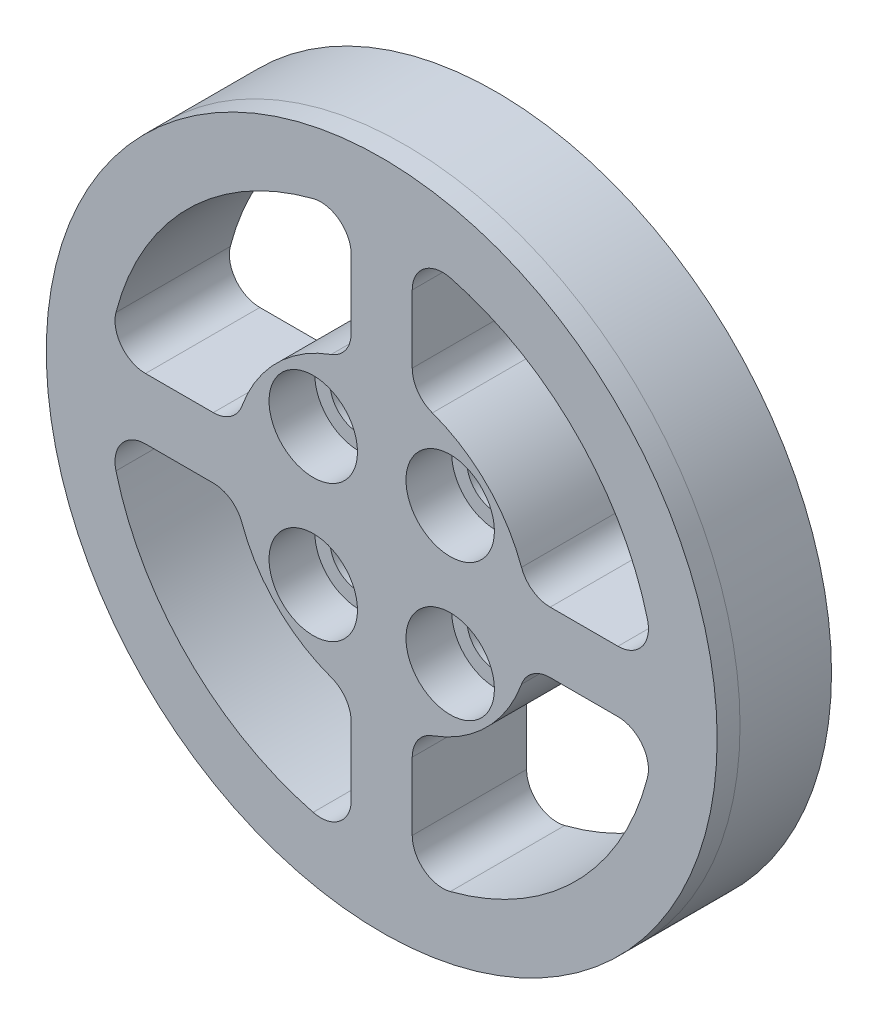
from build123d import *

# Parameters (mm, degrees)
SKETCH1_R           = 22
BOSS_EXTRUDE1_DEPTH = 6
BOSS_EXTRUDE2_DEPTH = 1.5
SKETCH3_R           = 1.375
BOSS_EXTRUDE3_DEPTH = 2.5
CUT_EXTRUDE3_REACH  = 12
SKETCH6_R           = 1.9
SKETCH7_R           = 2.9
CUT_EXTRUDE4_DEPTH  = 3
CUT_EXTRUDE5_START  = -1.5
SKETCH8_R           = 23.24877744
SKETCH8_R_2         = 22.000061981
CUT_EXTRUDE5_DEPTH  = 1.5


with BuildPart() as part:
    # Sketch1 → Boss-Extrude1 (new body)
    with BuildSketch(Plane.XY):
        Circle(SKETCH1_R)
        with BuildLine():
            Line((11.048189897, 2), (15.491933385, 2))
            ThreePointArc((15.491933385, 2), (17.073072215, 2.775255129), (17.428425058, 4.5))
            ThreePointArc((17.428425058, 4.5), (12.727922061, 12.727922061), (4.5, 17.428425058))
            ThreePointArc((4.5, 17.428425058), (2.775255129, 17.073072215), (2, 15.491933385))
            Line((2, 15.491933385), (2, 11.048189897))
            ThreePointArc((2, 11.048189897), (2.362669531, 9.899647805), (3.319148936, 9.167646936))
            ThreePointArc((3.319148936, 9.167646936), (6.894291117, 6.894291117), (9.167646936, 3.319148936))
            ThreePointArc((9.167646936, 3.319148936), (9.899647805, 2.362669531), (11.048189897, 2))
        make_face(mode=Mode.SUBTRACT)
        with BuildLine():
            Line((-15.491933385, 2), (-11.048189897, 2))
            ThreePointArc((-11.048189897, 2), (-9.899647805, 2.362669531), (-9.167646936, 3.319148936))
            ThreePointArc((-9.167646936, 3.319148936), (-6.894291117, 6.894291117), (-3.319148936, 9.167646936))
            ThreePointArc((-3.319148936, 9.167646936), (-2.362669531, 9.899647805), (-2, 11.048189897))
            Line((-2, 11.048189897), (-2, 15.491933385))
            ThreePointArc((-2, 15.491933385), (-2.775255129, 17.073072215), (-4.5, 17.428425058))
            ThreePointArc((-4.5, 17.428425058), (-12.727922061, 12.727922061), (-17.428425058, 4.5))
            ThreePointArc((-17.428425058, 4.5), (-17.073072215, 2.775255129), (-15.491933385, 2))
        make_face(mode=Mode.SUBTRACT)
        with BuildLine():
            Line((2, -11.048189897), (2, -15.491933385))
            ThreePointArc((2, -15.491933385), (2.775255129, -17.073072215), (4.5, -17.428425058))
            ThreePointArc((4.5, -17.428425058), (12.727922061, -12.727922061), (17.428425058, -4.5))
            ThreePointArc((17.428425058, -4.5), (17.073072215, -2.775255129), (15.491933385, -2))
            Line((15.491933385, -2), (11.048189897, -2))
            ThreePointArc((11.048189897, -2), (9.899647805, -2.362669531), (9.167646936, -3.319148936))
            ThreePointArc((9.167646936, -3.319148936), (6.894291117, -6.894291117), (3.319148936, -9.167646936))
            ThreePointArc((3.319148936, -9.167646936), (2.362669531, -9.899647805), (2, -11.048189897))
        make_face(mode=Mode.SUBTRACT)
        with BuildLine():
            Line((-15.491933385, -2), (-11.048189897, -2))
            ThreePointArc((-11.048189897, -2), (-9.899647805, -2.362669531), (-9.167646936, -3.319148936))
            ThreePointArc((-9.167646936, -3.319148936), (-6.894291117, -6.894291117), (-3.319148936, -9.167646936))
            ThreePointArc((-3.319148936, -9.167646936), (-2.362669531, -9.899647805), (-2, -11.048189897))
            Line((-2, -11.048189897), (-2, -15.491933385))
            ThreePointArc((-2, -15.491933385), (-2.775255129, -17.073072215), (-4.5, -17.428425058))
            ThreePointArc((-4.5, -17.428425058), (-12.727922061, -12.727922061), (-17.428425058, -4.5))
            ThreePointArc((-17.428425058, -4.5), (-17.073072215, -2.775255129), (-15.491933385, -2))
        make_face(mode=Mode.SUBTRACT)
    extrude(amount=BOSS_EXTRUDE1_DEPTH)

    # Sketch2 → Boss-Extrude2 (add)
    with BuildSketch(Plane.XY.offset(6)):
        with BuildLine():
            Line((-4.587705573, 22.79163465), (-6.529589207, 22.313003321))
            ThreePointArc((-6.529589207, 22.313003321), (-6.910364179, 21.255540917), (-7.801329494, 20.570415293))
            ThreePointArc((-7.801329494, 20.570415293), (-8.922548934, 20.492419898), (-9.908790373, 21.031441363))
            Line((-9.908790373, 21.031441363), (-11.679702424, 20.101995018))
            ThreePointArc((-11.679702424, 20.101995018), (-11.796345449, 18.984135135), (-12.497459637, 18.105696059))
            ThreePointArc((-12.497459637, 18.105696059), (-13.567432959, 17.761641694), (-14.654012294, 18.048977149))
            Line((-14.654012294, 18.048977149), (-16.15103379, 16.722731833))
            ThreePointArc((-16.15103379, 16.722731833), (-15.996766, 15.609440423), (-16.467282853, 14.588739582))
            ThreePointArc((-16.467282853, 14.588739582), (-17.423827096, 13.998621436), (-18.547596285, 14.017571989))
            Line((-18.547596285, 14.017571989), (-19.683725779, 12.371604258))
            ThreePointArc((-19.683725779, 12.371604258), (-19.267512657, 11.327581771), (-19.480087446, 10.223938589))
            ThreePointArc((-19.480087446, 10.223938589), (-20.267611735, 9.422052183), (-21.363261398, 9.171516497))
            Line((-21.363261398, 9.171516497), (-22.072471173, 7.301484012))
            ThreePointArc((-22.072471173, 7.301484012), (-21.418501513, 6.387405241), (-21.360780164, 5.264959447))
            ThreePointArc((-21.360780164, 5.264959447), (-21.93351645, 4.297907504), (-22.937371411, 3.792445804))
            Line((-22.937371411, 3.792445804), (-23.178444772, 1.807028055))
            ThreePointArc((-23.178444772, 1.807028055), (-22.324724914, 1.076015936), (-22.000061981, 0))
            ThreePointArc((-22.000061981, 0), (-22.324724914, -1.076015936), (-23.178444772, -1.807028055))
            Line((-23.178444772, -1.807028055), (-22.937371411, -3.792445804))
            ThreePointArc((-22.937371411, -3.792445804), (-21.93351645, -4.297907504), (-21.360780164, -5.264959447))
            ThreePointArc((-21.360780164, -5.264959447), (-21.418501513, -6.387405241), (-22.072471173, -7.301484012))
            Line((-22.072471173, -7.301484012), (-21.363261398, -9.171516497))
            ThreePointArc((-21.363261398, -9.171516497), (-20.267611735, -9.422052183), (-19.480087446, -10.223938589))
            ThreePointArc((-19.480087446, -10.223938589), (-19.267512657, -11.327581771), (-19.683725779, -12.371604258))
            Line((-19.683725779, -12.371604258), (-18.547596285, -14.017571989))
            ThreePointArc((-18.547596285, -14.017571989), (-17.423827096, -13.998621436), (-16.467282853, -14.588739582))
            ThreePointArc((-16.467282853, -14.588739582), (-15.996766, -15.609440423), (-16.15103379, -16.722731833))
            Line((-16.15103379, -16.722731833), (-14.654012294, -18.048977149))
            ThreePointArc((-14.654012294, -18.048977149), (-13.567432959, -17.761641694), (-12.497459637, -18.105696059))
            ThreePointArc((-12.497459637, -18.105696059), (-11.796345449, -18.984135135), (-11.679702424, -20.101995018))
            Line((-11.679702424, -20.101995018), (-9.908790373, -21.031441363))
            ThreePointArc((-9.908790373, -21.031441363), (-8.922548934, -20.492419898), (-7.801329494, -20.570415293))
            ThreePointArc((-7.801329494, -20.570415293), (-6.910364179, -21.255540917), (-6.529589207, -22.313003321))
            Line((-6.529589207, -22.313003321), (-4.587705573, -22.79163465))
            ThreePointArc((-4.587705573, -22.79163465), (-3.759118797, -22.032253145), (-2.651814437, -21.839656759))
            ThreePointArc((-2.651814437, -21.839656759), (-1.62277766, -22.291651923), (-1, -23.227260976))
            Line((-1, -23.227260976), (1, -23.227260976))
            ThreePointArc((1, -23.227260976), (1.62277766, -22.291651923), (2.651814437, -21.839656759))
            ThreePointArc((2.651814437, -21.839656759), (3.759118797, -22.032253145), (4.587705573, -22.79163465))
            Line((4.587705573, -22.79163465), (6.529589207, -22.313003321))
            ThreePointArc((6.529589207, -22.313003321), (6.910364179, -21.255540917), (7.801329494, -20.570415293))
            ThreePointArc((7.801329494, -20.570415293), (8.922548934, -20.492419898), (9.908790373, -21.031441363))
            Line((9.908790373, -21.031441363), (11.679702424, -20.101995018))
            ThreePointArc((11.679702424, -20.101995018), (11.796345449, -18.984135135), (12.497459637, -18.105696059))
            ThreePointArc((12.497459637, -18.105696059), (13.567432959, -17.761641694), (14.654012294, -18.048977149))
            Line((14.654012294, -18.048977149), (16.15103379, -16.722731833))
            ThreePointArc((16.15103379, -16.722731833), (15.996766, -15.609440423), (16.467282853, -14.588739582))
            ThreePointArc((16.467282853, -14.588739582), (17.423827096, -13.998621436), (18.547596285, -14.017571989))
            Line((18.547596285, -14.017571989), (19.683725779, -12.371604258))
            ThreePointArc((19.683725779, -12.371604258), (19.267512657, -11.327581771), (19.480087446, -10.223938589))
            ThreePointArc((19.480087446, -10.223938589), (20.267611735, -9.422052183), (21.363261398, -9.171516497))
            Line((21.363261398, -9.171516497), (22.072471173, -7.301484012))
            ThreePointArc((22.072471173, -7.301484012), (21.418501513, -6.387405241), (21.360780164, -5.264959447))
            ThreePointArc((21.360780164, -5.264959447), (21.93351645, -4.297907504), (22.937371411, -3.792445804))
            Line((22.937371411, -3.792445804), (23.178444772, -1.807028055))
            ThreePointArc((23.178444772, -1.807028055), (22.324724914, -1.076015936), (22.000061981, 0))
            ThreePointArc((22.000061981, 0), (22.324724914, 1.076015936), (23.178444772, 1.807028055))
            Line((23.178444772, 1.807028055), (22.937371411, 3.792445804))
            ThreePointArc((22.937371411, 3.792445804), (21.93351645, 4.297907504), (21.360780164, 5.264959447))
            ThreePointArc((21.360780164, 5.264959447), (21.418501513, 6.387405241), (22.072471173, 7.301484012))
            Line((22.072471173, 7.301484012), (21.363261398, 9.171516497))
            ThreePointArc((21.363261398, 9.171516497), (20.267611735, 9.422052183), (19.480087446, 10.223938589))
            ThreePointArc((19.480087446, 10.223938589), (19.267512657, 11.327581771), (19.683725779, 12.371604258))
            Line((19.683725779, 12.371604258), (18.547596285, 14.017571989))
            ThreePointArc((18.547596285, 14.017571989), (17.423827096, 13.998621436), (16.467282853, 14.588739582))
            ThreePointArc((16.467282853, 14.588739582), (15.996766, 15.609440423), (16.15103379, 16.722731833))
            Line((16.15103379, 16.722731833), (14.654012294, 18.048977149))
            ThreePointArc((14.654012294, 18.048977149), (13.567432959, 17.761641694), (12.497459637, 18.105696059))
            ThreePointArc((12.497459637, 18.105696059), (11.796345449, 18.984135135), (11.679702424, 20.101995018))
            Line((11.679702424, 20.101995018), (9.908790373, 21.031441363))
            ThreePointArc((9.908790373, 21.031441363), (8.922548934, 20.492419898), (7.801329494, 20.570415293))
            ThreePointArc((7.801329494, 20.570415293), (6.910364179, 21.255540917), (6.529589207, 22.313003321))
            Line((6.529589207, 22.313003321), (4.587705573, 22.79163465))
            ThreePointArc((4.587705573, 22.79163465), (3.759118797, 22.032253145), (2.651814437, 21.839656759))
            ThreePointArc((2.651814437, 21.839656759), (1.62277766, 22.291651923), (1, 23.227260976))
            Line((1, 23.227260976), (-1, 23.227260976))
            ThreePointArc((-1, 23.227260976), (-1.62277766, 22.291651923), (-2.651814437, 21.839656759))
            ThreePointArc((-2.651814437, 21.839656759), (-3.759118797, 22.032253145), (-4.587705573, 22.79163465))
        make_face()
        with BuildLine():
            Line((-2, 11.048189897), (-2, 15.491933385))
            ThreePointArc((-2, 15.491933385), (-2.775255129, 17.073072215), (-4.5, 17.428425058))
            ThreePointArc((-4.5, 17.428425058), (-12.727922061, 12.727922061), (-17.428425058, 4.5))
            ThreePointArc((-17.428425058, 4.5), (-17.073072215, 2.775255129), (-15.491933385, 2))
            Line((-15.491933385, 2), (-11.048189897, 2))
            ThreePointArc((-11.048189897, 2), (-9.899647805, 2.362669531), (-9.167646936, 3.319148936))
            ThreePointArc((-9.167646936, 3.319148936), (-6.894291117, 6.894291117), (-3.319148936, 9.167646936))
            ThreePointArc((-3.319148936, 9.167646936), (-2.362669531, 9.899647805), (-2, 11.048189897))
        make_face(mode=Mode.SUBTRACT)
        with BuildLine():
            Line((2, 15.491933385), (2, 11.048189897))
            ThreePointArc((2, 11.048189897), (2.362669531, 9.899647805), (3.319148936, 9.167646936))
            ThreePointArc((3.319148936, 9.167646936), (6.894291117, 6.894291117), (9.167646936, 3.319148936))
            ThreePointArc((9.167646936, 3.319148936), (9.899647805, 2.362669531), (11.048189897, 2))
            Line((11.048189897, 2), (15.491933385, 2))
            ThreePointArc((15.491933385, 2), (17.073072215, 2.775255129), (17.428425058, 4.5))
            ThreePointArc((17.428425058, 4.5), (12.727922061, 12.727922061), (4.5, 17.428425058))
            ThreePointArc((4.5, 17.428425058), (2.775255129, 17.073072215), (2, 15.491933385))
        make_face(mode=Mode.SUBTRACT)
        with BuildLine():
            Line((2, -11.048189897), (2, -15.491933385))
            ThreePointArc((2, -15.491933385), (2.775255129, -17.073072215), (4.5, -17.428425058))
            ThreePointArc((4.5, -17.428425058), (12.727922061, -12.727922061), (17.428425058, -4.5))
            ThreePointArc((17.428425058, -4.5), (17.073072215, -2.775255129), (15.491933385, -2))
            Line((15.491933385, -2), (11.048189897, -2))
            ThreePointArc((11.048189897, -2), (9.899647805, -2.362669531), (9.167646936, -3.319148936))
            ThreePointArc((9.167646936, -3.319148936), (6.894291117, -6.894291117), (3.319148936, -9.167646936))
            ThreePointArc((3.319148936, -9.167646936), (2.362669531, -9.899647805), (2, -11.048189897))
        make_face(mode=Mode.SUBTRACT)
        with BuildLine():
            Line((-11.048189897, -2), (-15.491933385, -2))
            ThreePointArc((-15.491933385, -2), (-17.073072215, -2.775255129), (-17.428425058, -4.5))
            ThreePointArc((-17.428425058, -4.5), (-12.727922061, -12.727922061), (-4.5, -17.428425058))
            ThreePointArc((-4.5, -17.428425058), (-2.775255129, -17.073072215), (-2, -15.491933385))
            Line((-2, -15.491933385), (-2, -11.048189897))
            ThreePointArc((-2, -11.048189897), (-2.362669531, -9.899647805), (-3.319148936, -9.167646936))
            ThreePointArc((-3.319148936, -9.167646936), (-6.894291117, -6.894291117), (-9.167646936, -3.319148936))
            ThreePointArc((-9.167646936, -3.319148936), (-9.899647805, -2.362669531), (-11.048189897, -2))
        make_face(mode=Mode.SUBTRACT)
    extrude(amount=BOSS_EXTRUDE2_DEPTH)

    # Sketch3 → Boss-Extrude3 (add)
    with BuildSketch(Plane(origin=(0, 0, 0), x_dir=(-1, 0, 0), z_dir=(0, 0, -1))):
        with Locations((8, 0)):
            Circle(SKETCH3_R)
        with Locations((0, 8)):
            Circle(SKETCH3_R)
        with Locations((-8, 0)):
            Circle(SKETCH3_R)
        with Locations((0, -8)):
            Circle(SKETCH3_R)
    extrude(amount=BOSS_EXTRUDE3_DEPTH)

    # Sketch6 → Cut-Extrude3 (cut, up to next)
    with BuildSketch(Plane.XY.offset(7.5), mode=Mode.PRIVATE) as cut_extrude3_sk1:
        with Locations((4.490128061, 4.490128061)):
            Circle(SKETCH6_R)
    cut_extrude3_tool1 = extrude(cut_extrude3_sk1.sketch, amount=-CUT_EXTRUDE3_REACH, mode=Mode.PRIVATE) & part.part
    add(cut_extrude3_tool1.solids().sort_by_distance((4.490128, 4.490128, 7.5))[0], mode=Mode.SUBTRACT)
    # Sketch6 → Cut-Extrude3 (cut, up to next)
    with BuildSketch(Plane.XY.offset(7.5), mode=Mode.PRIVATE) as cut_extrude3_sk2:
        with Locations((-4.490128061, 4.490128061)):
            Circle(SKETCH6_R)
    cut_extrude3_tool2 = extrude(cut_extrude3_sk2.sketch, amount=-CUT_EXTRUDE3_REACH, mode=Mode.PRIVATE) & part.part
    add(cut_extrude3_tool2.solids().sort_by_distance((-4.490128, 4.490128, 7.5))[0], mode=Mode.SUBTRACT)
    # Sketch6 → Cut-Extrude3 (cut, up to next)
    with BuildSketch(Plane.XY.offset(7.5), mode=Mode.PRIVATE) as cut_extrude3_sk3:
        with Locations((4.490128061, -4.490128061)):
            Circle(SKETCH6_R)
    cut_extrude3_tool3 = extrude(cut_extrude3_sk3.sketch, amount=-CUT_EXTRUDE3_REACH, mode=Mode.PRIVATE) & part.part
    add(cut_extrude3_tool3.solids().sort_by_distance((4.490128, -4.490128, 7.5))[0], mode=Mode.SUBTRACT)
    # Sketch6 → Cut-Extrude3 (cut, up to next)
    with BuildSketch(Plane.XY.offset(7.5), mode=Mode.PRIVATE) as cut_extrude3_sk4:
        with Locations((-4.490128061, -4.490128061)):
            Circle(SKETCH6_R)
    cut_extrude3_tool4 = extrude(cut_extrude3_sk4.sketch, amount=-CUT_EXTRUDE3_REACH, mode=Mode.PRIVATE) & part.part
    add(cut_extrude3_tool4.solids().sort_by_distance((-4.490128, -4.490128, 7.5))[0], mode=Mode.SUBTRACT)

    # Sketch7 → Cut-Extrude4 (cut)
    with BuildSketch(Plane.XY.offset(7.5)):
        with Locations((-4.490128061, 4.490128061)):
            Circle(SKETCH7_R)
        with Locations((4.490128061, 4.490128061)):
            Circle(SKETCH7_R)
        with Locations((4.490128061, -4.490128061)):
            Circle(SKETCH7_R)
        with Locations((-4.490128061, -4.490128061)):
            Circle(SKETCH7_R)
    extrude(amount=-CUT_EXTRUDE4_DEPTH, mode=Mode.SUBTRACT)

    # Sketch8 → Cut-Extrude5 (cut)
    with BuildSketch(Plane.XY.offset(7.5).offset(CUT_EXTRUDE5_START)):
        Circle(SKETCH8_R)
        Circle(SKETCH8_R_2, mode=Mode.SUBTRACT)
    extrude(amount=CUT_EXTRUDE5_DEPTH, mode=Mode.SUBTRACT)


solid = part.part
